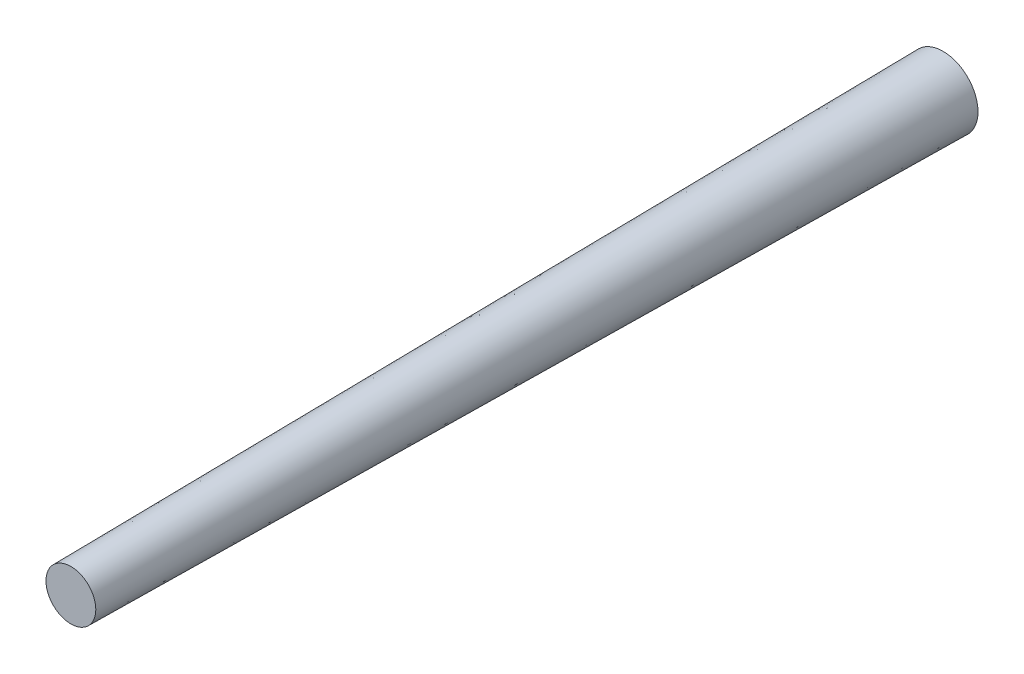
from build123d import *

# Parameters (mm, degrees)
SKETCH3_R = 2.54
SKETCH2_R = 3.556


with BuildPart() as part:
    # Sketch3 → Loft1 section 0
    with BuildSketch(Plane.XY.offset(88.9)):
        Circle(SKETCH3_R)
    # Sketch2 → Loft1 section 1
    with BuildSketch(Plane.XY):
        Circle(SKETCH2_R)
    loft()


solid = part.part
